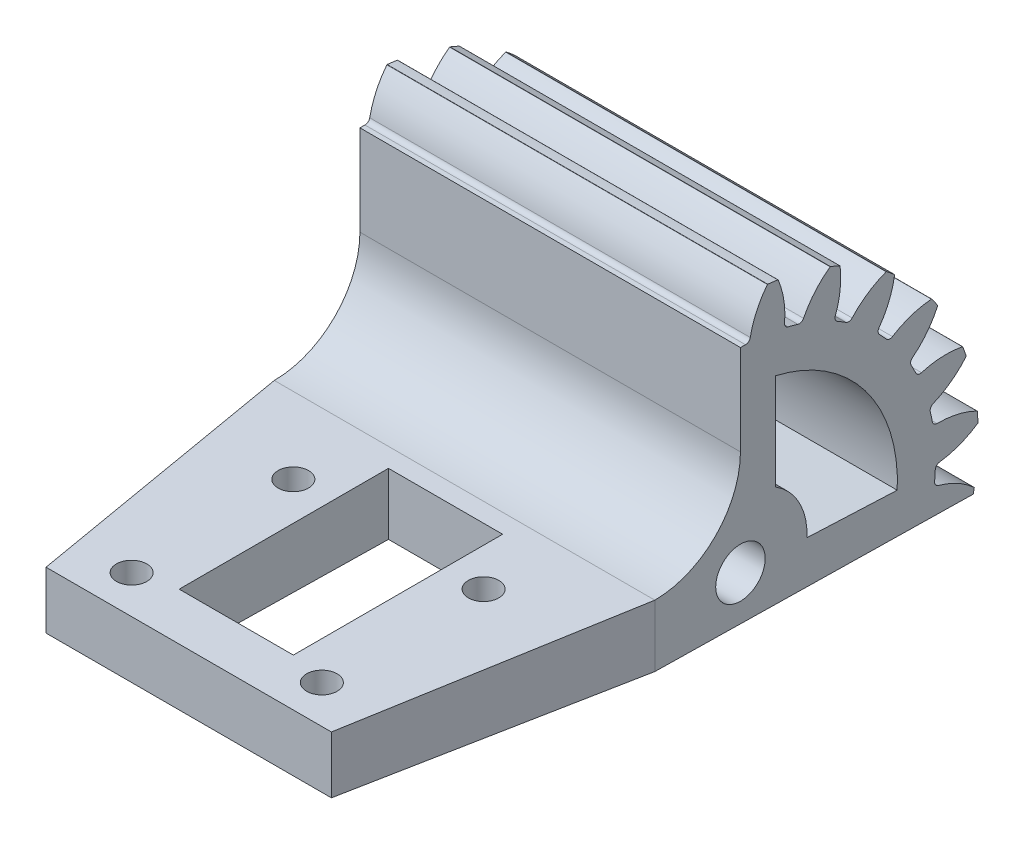
from build123d import *

# Parameters (mm, degrees)
BASPROSKE_W                = 40
BASPROSKE_H                = 25
TOOTHCUT_DEPTH             = 41
BREAKS_R                   = 0.04
ROOTFILLETS_R              = 0.501
TEETHCUTS_COUNT            = 23
TEETHCUTS_ANGLE            = 344.347826087
BREAKS_OF_TEETHCUTS_R      = 0.04
ROOTFILLETS_OF_TEETHCUTS_R = 0.501
BORSKE_R                   = 0.4
BORE_DEPTH                 = 50.0000508
CUT_EXTRUDE_1_DEPTH        = 41.0000001
SKETCH_3_R                 = 1.6
CUT_EXTRUDE_2_DEPTH        = 41.0000001
EXTRUDE_1_DEPTH            = 40
SKETCH_5_R                 = 1.6
CUT_EXTRUDE_3_DEPTH        = 8.086400426
CUT_EXTRUDE_5_DEPTH        = 41.0000001
SKETCH_8_W                 = 12
SKETCH_8_H                 = 22
CUT_EXTRUDE_6_DEPTH        = 8.086400426
SKETCH_10_R                = 2.6
CUT_EXTRUDE_7_DEPTH        = 41.0000001
CUT_EXTRUDE_8_DEPTH        = 8.086400426


with BuildPart() as part:
    # BasProSke → Base-Revolve (revolve)
    with BuildSketch(Plane(origin=(0, 0, 0), x_dir=(1, 0, 0), z_dir=(0, 1, 0))):
        with Locations((20, 12.5)):
            Rectangle(BASPROSKE_W, BASPROSKE_H)
    revolve(axis=Axis((-10, 0, 0), (1, 0, 0)))

    # TooCutSke → ToothCut (cut, through all)
    with BuildSketch(Plane(origin=(0, 0, 0), x_dir=(0, 0, -1), z_dir=(1, 0, 0))):
        with BuildLine():
            ThreePointArc((0.960248578, 20.47649686), (0, 20.499), (-0.960248578, 20.47649686))
            ThreePointArc((-0.960248578, 20.47649686), (-1.62297083, 22.794554384), (-2.865164893, 24.860842208))
            ThreePointArc((-2.865164893, 24.860842208), (0, 25.0254), (2.865164893, 24.860842208))
            ThreePointArc((2.865164893, 24.860842208), (1.62297083, 22.794554384), (0.960248578, 20.47649686))
        make_face()
    toothcut = extrude(amount=TOOTHCUT_DEPTH, mode=Mode.SUBTRACT)

    # Breaks
    breaks_edges = [part.edges().sort_by_distance(p)[0] for p in [
        (20, 24.837412953, -2.846562451),
        (20, 24.837412953, 2.846562451),
    ]]
    fillet(breaks_edges, radius=BREAKS_R)

    # RootFillets
    rootfillets_edges = [part.edges().sort_by_distance(p)[0] for p in [
        (20, 20.47649686, -0.960248578),
        (20, 20.47649686, 0.960248578),
    ]]
    fillet(rootfillets_edges, radius=ROOTFILLETS_R)

    # TeethCuts: ToothCut ×23 about axis
    teethcuts_axis = Axis((-10, 0, 0), (1, 0, 0))
    for i in range(1, TEETHCUTS_COUNT):
        add(toothcut.rotate(teethcuts_axis, i * TEETHCUTS_ANGLE / (TEETHCUTS_COUNT - 1)), mode=Mode.SUBTRACT)

    # Breaks of TeethCuts
    breaks_of_teethcuts_edges = [part.edges().sort_by_distance(p)[0] for p in [
        (20, 24.684367664, 3.960049625),
        (20, 23.148380948, 9.442058012),
        (20, 22.700595748, 10.472962937),
        (20, 19.742539424, 15.337279325),
        (20, 19.033224494, 16.209144498),
        (20, 14.872484067, 20.095004794),
        (20, 13.954246051, 20.743167963),
        (20, 8.899404604, 23.362375686),
        (20, 7.840345014, 23.738765555),
        (20, 2.266297014, 24.897066049),
        (20, 1.144961455, 24.973767502),
        (20, -4.534891458, 24.58525492),
        (20, -5.635338658, 24.356579362),
        (20, -10.999747777, 22.450067903),
        (20, -11.997691482, 21.932975154),
        (20, -16.648803123, 18.649862052),
        (20, -17.470230414, 17.882702516),
        (20, -21.063092905, 13.46648125),
        (20, -21.647082278, 12.50615164),
        (20, -23.915229444, 7.284353139),
        (20, -24.218469078, 6.202076708),
        (20, -24.993682819, 0.56197788),
        (20, -24.993682819, -0.56197788),
        (20, -24.218469078, -6.202076708),
        (20, -23.915229444, -7.284353139),
        (20, -21.647082278, -12.50615164),
        (20, -21.063092905, -13.46648125),
        (20, -17.470230414, -17.882702516),
        (20, -16.648803123, -18.649862052),
        (20, -11.997691482, -21.932975154),
        (20, -10.999747777, -22.450067903),
        (20, -5.635338658, -24.356579362),
        (20, -4.534891458, -24.58525492),
        (20, 1.144961455, -24.973767502),
        (20, 2.266297014, -24.897066049),
        (20, 7.840345014, -23.738765555),
        (20, 8.899404604, -23.362375686),
        (20, 13.954246051, -20.743167963),
        (20, 14.872484067, -20.095004794),
        (20, 19.033224494, -16.209144498),
        (20, 19.742539424, -15.337279325),
        (20, 22.700595748, -10.472962937),
        (20, 23.148380948, -9.442058012),
        (20, 24.684367664, -3.960049625),
    ]]
    fillet(breaks_of_teethcuts_edges, radius=BREAKS_OF_TEETHCUTS_R)

    # RootFillets of TeethCuts
    rootfillets_of_teethcuts_edges = [part.edges().sort_by_distance(p)[0] for p in [
        (20, 19.976244777, 4.599852781),
        (20, 19.458100845, 6.449132694),
        (20, 17.994446004, 9.818804103),
        (20, 16.996586505, 11.45971414),
        (20, 14.67808149, 14.309539642),
        (20, 13.274513098, 15.620381013),
        (20, 10.273110819, 17.739002088),
        (20, 8.567929782, 18.622555685),
        (20, 5.106230516, 19.8528439),
        (20, 3.225902309, 20.243580595),
        (20, -0.439355546, 20.4942911),
        (20, -2.35537558, 20.363231739),
        (20, -5.952356616, 19.615770485),
        (20, -7.761966038, 18.972635142),
        (20, -11.023898627, 17.282437909),
        (20, -12.592886984, 16.17492499),
        (20, -15.277848507, 13.667345975),
        (20, -16.48985111, 12.177594646),
        (20, -18.398710255, 9.038609514),
        (20, -19.163838416, 7.277107817),
        (20, -20.155023832, 3.739520734),
        (20, -20.416531495, 1.836911191),
        (20, -20.416531495, -1.836911191),
        (20, -20.155023832, -3.739520734),
        (20, -19.163838416, -7.277107817),
        (20, -18.398710255, -9.038609514),
        (20, -16.48985111, -12.177594646),
        (20, -15.277848507, -13.667345975),
        (20, -12.592886984, -16.17492499),
        (20, -11.023898627, -17.282437909),
        (20, -7.761966038, -18.972635142),
        (20, -5.952356616, -19.615770485),
        (20, -2.35537558, -20.363231739),
        (20, -0.439355546, -20.4942911),
        (20, 3.225902309, -20.243580595),
        (20, 5.106230516, -19.8528439),
        (20, 8.567929782, -18.622555685),
        (20, 10.273110819, -17.739002088),
        (20, 13.274513098, -15.620381013),
        (20, 14.67808149, -14.309539642),
        (20, 16.996586505, -11.45971414),
        (20, 17.994446004, -9.818804103),
        (20, 19.458100845, -6.449132694),
        (20, 19.976244777, -4.599852781),
    ]]
    fillet(rootfillets_of_teethcuts_edges, radius=ROOTFILLETS_OF_TEETHCUTS_R)

    # BorSke → Bore (cut, symmetric)
    with BuildSketch(Plane(origin=(0, 0, 0), x_dir=(0, 0, -1), z_dir=(1, 0, 0))):
        Circle(BORSKE_R)
    extrude(amount=BORE_DEPTH, both=True, mode=Mode.SUBTRACT)

    # 草图1 → 切除-拉伸1 (cut, through all)
    with BuildSketch(Plane(origin=(40, 0, 0), x_dir=(0, 0, -1), z_dir=(1, 0, 0))):
        Polygon((0, 25.40344831), (0, 0), (24.477102192, -5.086400326), (36.223845709, -7.527401699), (19.523748117, -38.1691479), (-51.092656089, -13.880281599), (-19.99747754, 29.428012733), align=None)
    extrude(amount=-CUT_EXTRUDE_1_DEPTH, mode=Mode.SUBTRACT)

    # 草图3 → 切除-拉伸2 (cut, through all)
    with BuildSketch(Plane.ZY):
        Circle(SKETCH_3_R)
    extrude(amount=-CUT_EXTRUDE_2_DEPTH, mode=Mode.SUBTRACT)

    # 草图4 → 凸台-拉伸1 (add)
    with BuildSketch(Plane.ZY):
        with BuildLine():
            Line((0, 11), (0, 4))
            Line((0, 4), (0, 1.6))
            ThreePointArc((0, 1.6), (1.241138065, -1.009740711), (-1.56653454, -0.325529621))
            Line((-1.56653454, -0.325529621), (-24.477102192, -5.086400326))
            Line((-24.477102192, -5.086400326), (37.999520255, -4))
            Line((37.999520255, -4), (37.999520255, 2))
            Line((37.999520255, 2), (15.999520255, 2))
            Line((15.999520255, 2), (9, 2))
            ThreePointArc((9, 2), (2.636038969, 4.636038969), (0, 11))
        make_face()
    extrude(amount=-EXTRUDE_1_DEPTH)

    # 草图5 → 切除-拉伸3 (cut, through all)
    with BuildSketch(Plane(origin=(0, 2, 0), x_dir=(1, 0, 0), z_dir=(0, 1, 0))):
        with Locations((10, -17)):
            Circle(SKETCH_5_R)
        with Locations((10, -34)):
            Circle(SKETCH_5_R)
        with Locations((30, -34)):
            Circle(SKETCH_5_R)
        with Locations((30, -17)):
            Circle(SKETCH_5_R)
    extrude(amount=-CUT_EXTRUDE_3_DEPTH, mode=Mode.SUBTRACT)

    # 草图7 → 切除-拉伸5 (cut, through all)
    with BuildSketch(Plane.ZY):
        with BuildLine():
            Line((-6.993115273, -0.310384892), (-16.483771715, -0.731621531))
            ThreePointArc((-16.483771715, -0.731621531), (-13.13305506, 9.988636784), (-3.696934599, 16.080506042))
            Line((-3.696934599, 16.080506042), (-3.696934599, 5.944129421))
            ThreePointArc((-3.696934599, 5.944129421), (-6.192659274, 3.263582558), (-6.993115273, -0.310384892))
        make_face()
    extrude(amount=-CUT_EXTRUDE_5_DEPTH, mode=Mode.SUBTRACT)

    # 草图8 → 切除-拉伸6 (cut, through all)
    with BuildSketch(Plane(origin=(0, 2, 0), x_dir=(1, 0, 0), z_dir=(0, 1, 0))):
        with Locations((20, -21.999520255)):
            Rectangle(SKETCH_8_W, SKETCH_8_H)
    extrude(amount=-CUT_EXTRUDE_6_DEPTH, mode=Mode.SUBTRACT)

    # 草图10 → 切除-拉伸7 (cut, through all)
    with BuildSketch(Plane.ZY):
        Circle(SKETCH_10_R)
    extrude(amount=-CUT_EXTRUDE_7_DEPTH, mode=Mode.SUBTRACT)

    # 草图11 → 切除-拉伸8 (cut, through all)
    with BuildSketch(Plane(origin=(0, 2, 0), x_dir=(1, 0, 0), z_dir=(0, 1, 0))):
        Polygon((35, -37.999520255), (40, -9), (40, -37.999520255), align=None)
        Polygon((0, -37.999520255), (5, -37.999520255), (0, -9), align=None)
    extrude(amount=-CUT_EXTRUDE_8_DEPTH, mode=Mode.SUBTRACT)


solid = part.part
